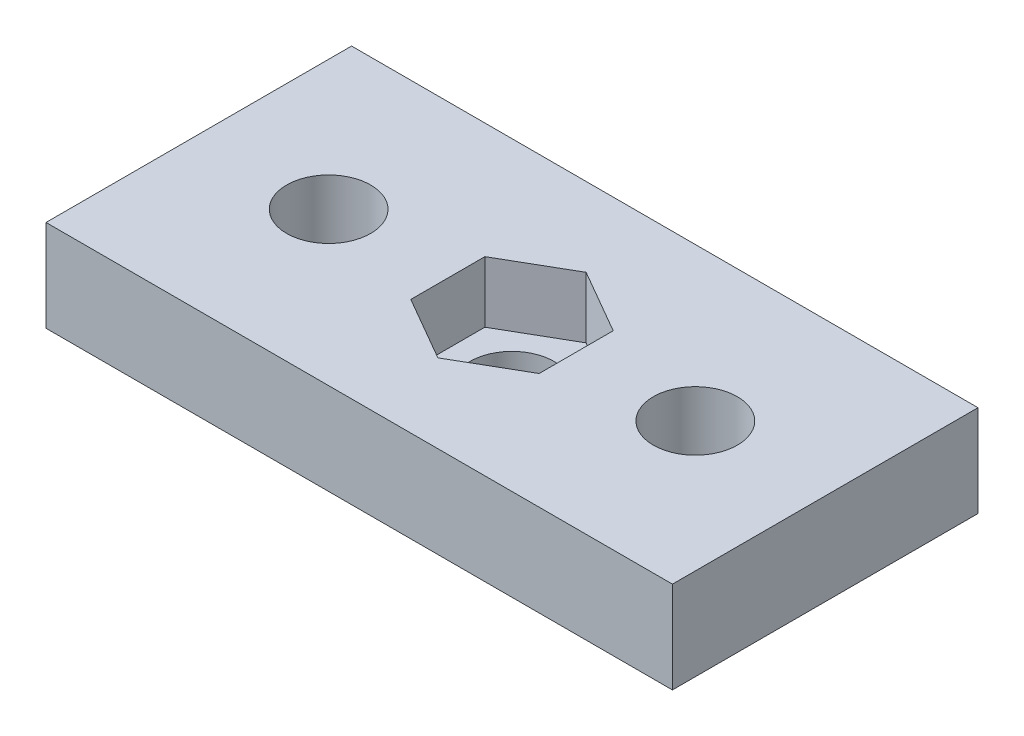
from build123d import *

# Parameters (mm, degrees)
SKETCH1_W           = 41
SKETCH1_H           = 20
BOSS_EXTRUDE1_DEPTH = 6
NUT_DEPTH           = 4
SKETCH7_R           = 2.75
HOLES_DEPTH         = 7


with BuildPart() as part:
    # Sketch1 → Boss-Extrude1 (new body)
    with BuildSketch(Plane(origin=(0, 0, 0), x_dir=(1, 0, 0), z_dir=(0, 1, 0))):
        with Locations((20.5, 10)):
            Rectangle(SKETCH1_W, SKETCH1_H)
    extrude(amount=-BOSS_EXTRUDE1_DEPTH)

    # Sketch2 → nut (cut)
    with BuildSketch(Plane(origin=(0, 0, 0), x_dir=(1, 0, 0), z_dir=(0, 1, 0))):
        Polygon((20.5, 5.150257739), (24.7, 7.575128869), (24.7, 12.424871131), (20.5, 14.849742261), (16.3, 12.424871131), (16.3, 7.575128869), align=None)
    extrude(amount=-NUT_DEPTH, mode=Mode.SUBTRACT)

    # Sketch7 → holes (cut, through all)
    with BuildSketch(Plane(origin=(0, 0, 0), x_dir=(1, 0, 0), z_dir=(0, 1, 0))):
        with Locations((8.5, 10)):
            Circle(SKETCH7_R)
        with Locations((32.5, 10)):
            Circle(SKETCH7_R)
        with Locations((20.5, 10)):
            Circle(SKETCH7_R)
    extrude(amount=-HOLES_DEPTH, mode=Mode.SUBTRACT)


solid = part.part
